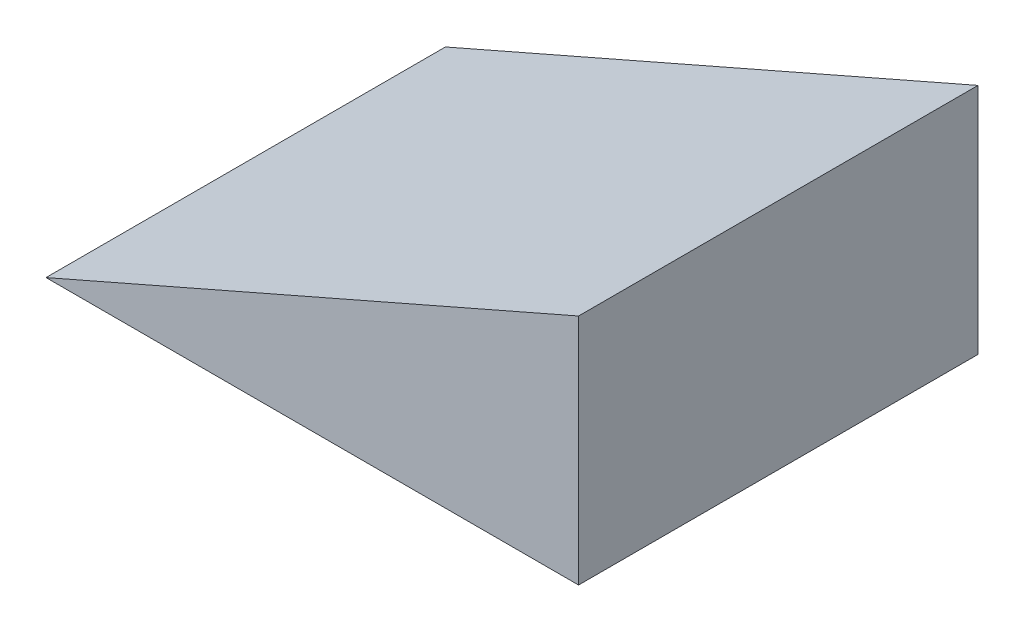
from build123d import *

# Parameters (mm, degrees)
BOSS_EXTRUDE1_DEPTH = 60


with BuildPart() as part:
    # Sketch1 → Boss-Extrude1 (new body)
    with BuildSketch(Plane.XY):
        Polygon((0, 0), (80, 35), (80, 0), align=None)
    extrude(amount=BOSS_EXTRUDE1_DEPTH)


solid = part.part
